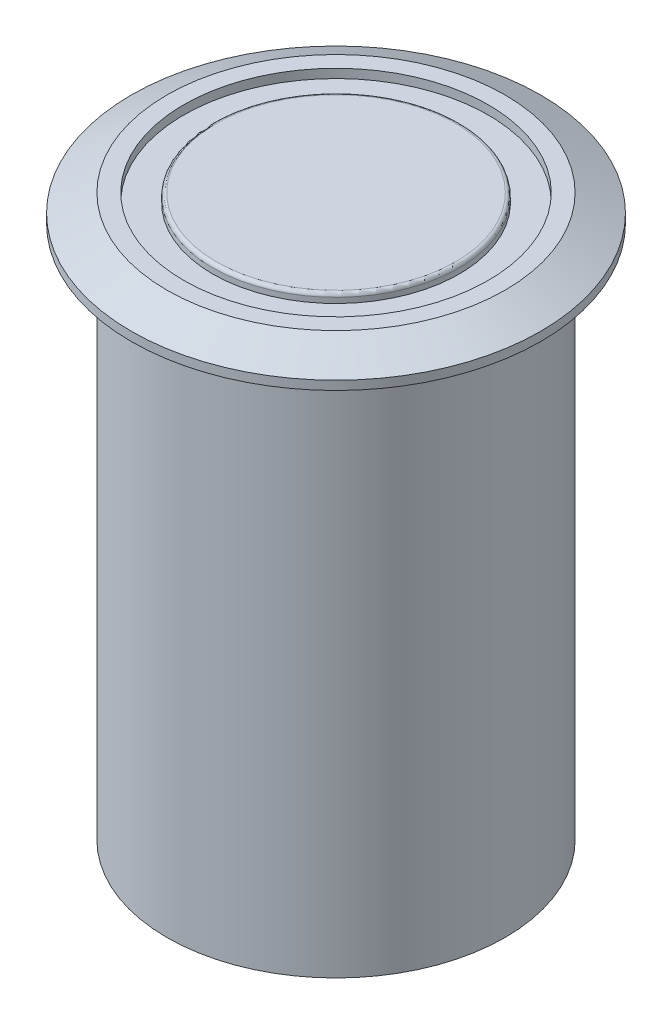
from build123d import *

# Parameters (mm, degrees)
SKETCH_1_R          = 9.5
EXTRUDE_1_DEPTH     = 30
SKETCH_2_R          = 11.5
EXTRUDE_2_DEPTH     = 1.5
CHAMFER_1_SIZE      = 1
CHAMFER_1_SIZE2     = 2
SKETCH_3_R          = 8.553523617
SKETCH_3_R_2        = 6.929138855
CUT_EXTRUDE_1_DEPTH = 0.5
FILLET_1_R          = 0.2


with BuildPart() as part:
    # 草图1 → 凸台-拉伸1 (new body)
    with BuildSketch(Plane(origin=(0, 0, 0), x_dir=(1, 0, 0), z_dir=(0, 1, 0))):
        Circle(SKETCH_1_R)
    extrude(amount=EXTRUDE_1_DEPTH)

    # 草图2 → 凸台-拉伸2 (add)
    with BuildSketch(Plane(origin=(0, 30, 0), x_dir=(1, 0, 0), z_dir=(0, 1, 0))):
        Circle(SKETCH_2_R)
    extrude(amount=EXTRUDE_2_DEPTH)

    # 倒角1
    chamfer_1_edges = [part.edges().sort_by_distance(p)[0] for p in [
        (-11.5, 31.5, 0),
    ]]
    chamfer_1_side = [part.faces().sort_by_distance(p)[0] for p in [
        (-11.5, 30.75, 0),
    ]]
    chamfer(chamfer_1_edges, length=CHAMFER_1_SIZE, length2=CHAMFER_1_SIZE2, reference=chamfer_1_side[0])

    # 草图3 → 切除-拉伸1 (cut)
    with BuildSketch(Plane(origin=(0, 31.5, 0), x_dir=(1, 0, 0), z_dir=(0, 1, 0))):
        Circle(SKETCH_3_R)
        Circle(SKETCH_3_R_2, mode=Mode.SUBTRACT)
    extrude(amount=-CUT_EXTRUDE_1_DEPTH, mode=Mode.SUBTRACT)

    # 圆角1
    fillet_1_edges = [part.edges().sort_by_distance(p)[0] for p in [
        (-6.929138855, 31.5, 0),
    ]]
    fillet(fillet_1_edges, radius=FILLET_1_R)


solid = part.part
